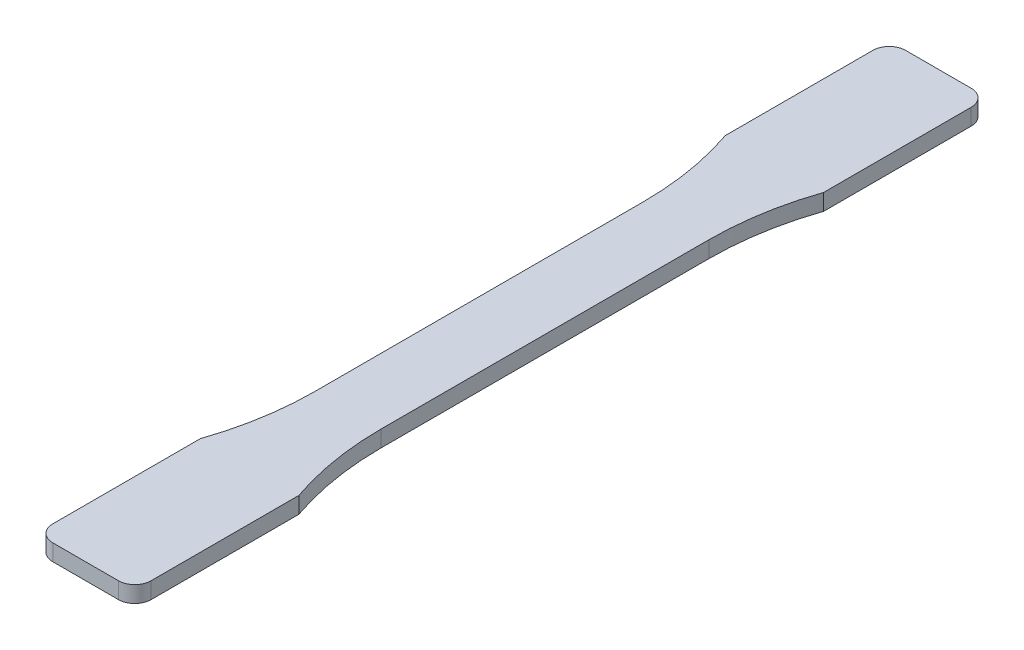
from build123d import *

# Parameters (mm, degrees)
BOSS_EXTRUDE1_DEPTH = 1.5875
FILLET1_R           = 3.175


with BuildPart() as part:
    # Sketch1 → Boss-Extrude1 (new body, symmetric)
    with BuildSketch(Plane(origin=(0, 0, 0), x_dir=(1, 0, 0), z_dir=(0, 1, 0))):
        with BuildLine():
            Line((6.35, 31.75), (6.35, -31.75))
            ThreePointArc((6.35, -31.75), (7.149186899, -41.406385517), (9.525, -50.8))
            Line((9.525, -50.8), (9.525, -82.55))
            Line((9.525, -82.55), (-9.525, -82.55))
            Line((-9.525, -82.55), (-9.525, -50.8))
            ThreePointArc((-9.525, -50.8), (-7.149186899, -41.406385517), (-6.35, -31.75))
            Line((-6.35, -31.75), (-6.35, 31.75))
            ThreePointArc((-6.35, 31.75), (-7.149186899, 41.406385517), (-9.525, 50.8))
            Line((-9.525, 50.8), (-9.525, 82.55))
            Line((-9.525, 82.55), (9.525, 82.55))
            Line((9.525, 82.55), (9.525, 50.8))
            ThreePointArc((9.525, 50.8), (7.149186899, 41.406385517), (6.35, 31.75))
        make_face()
    extrude(amount=BOSS_EXTRUDE1_DEPTH, both=True)

    # Fillet1
    fillet1_edges = [part.edges().sort_by_distance(p)[0] for p in [
        (9.525, 0, 82.55),
        (-9.525, 0, 82.55),
        (-9.525, 0, -82.55),
        (9.525, 0, -82.55),
    ]]
    fillet(fillet1_edges, radius=FILLET1_R)


solid = part.part
